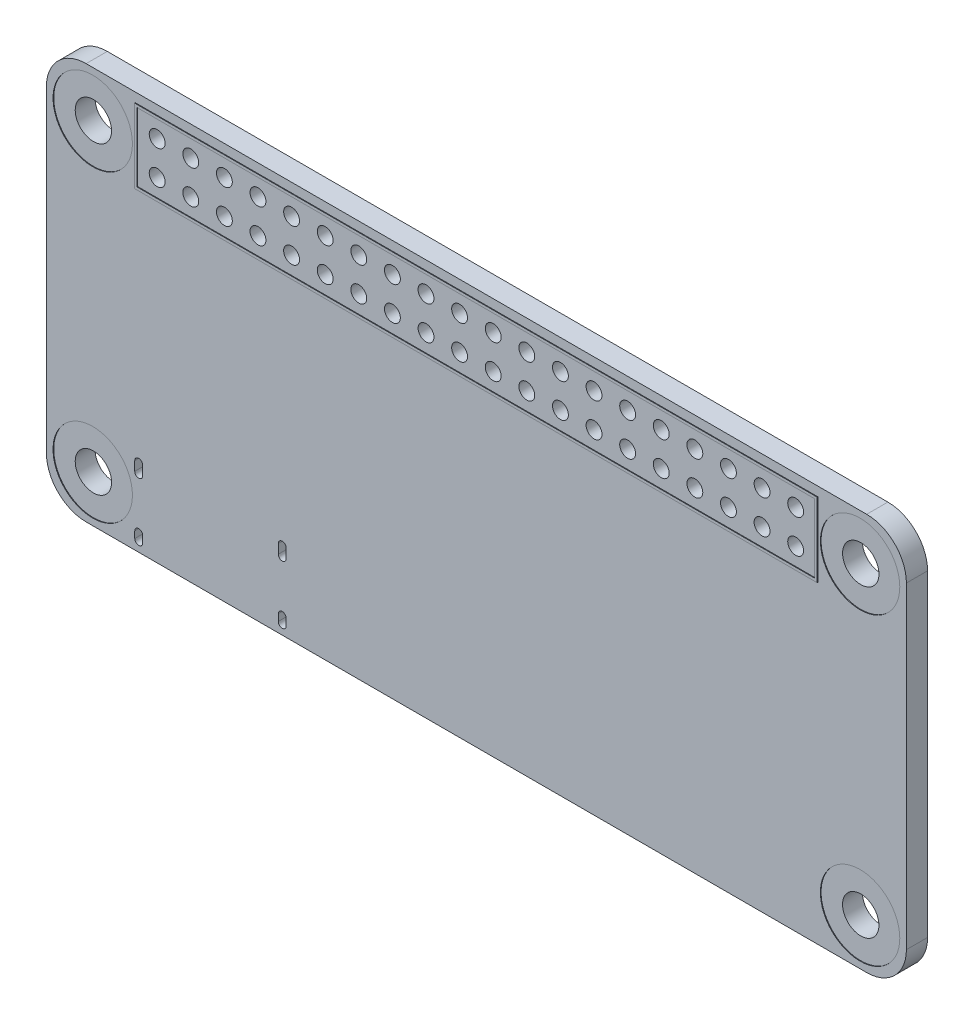
from build123d import *

# Parameters (mm, degrees)
SKETCH1_R           = 1.375
BOSS_EXTRUDE1_DEPTH = 1.6
SKETCH2_W           = 51.6
SKETCH2_H           = 5.6
SKETCH2_W_2         = 51.2
SKETCH2_H_2         = 5.2
EXTRUDE_THIN1_DEPTH = 0.05
SKETCH3_R           = 0.6
CUT_EXTRUDE1_DEPTH  = 1.6
SKETCH4_R           = 3
CUT_EXTRUDE2_DEPTH  = 0.05
SKETCH5_R           = 3
CUT_EXTRUDE3_DEPTH  = 0.05
CUT_EXTRUDE4_DEPTH  = 1.6


with BuildPart() as part:
    # Sketch1 → Boss-Extrude1 (new body)
    with BuildSketch(Plane.XY):
        with BuildLine():
            Line((-29.5, 15), (29.5, 15))
            ThreePointArc((29.5, 15), (31.621320344, 14.121320344), (32.5, 12))
            Line((32.5, 12), (32.5, -12))
            ThreePointArc((32.5, -12), (31.621320344, -14.121320344), (29.5, -15))
            Line((29.5, -15), (-29.5, -15))
            ThreePointArc((-29.5, -15), (-31.621320344, -14.121320344), (-32.5, -12))
            Line((-32.5, -12), (-32.5, 12))
            ThreePointArc((-32.5, 12), (-31.621320344, 14.121320344), (-29.5, 15))
        make_face()
        with Locations((-29, 11.5)):
            Circle(SKETCH1_R, mode=Mode.SUBTRACT)
        with Locations((29, 11.5)):
            Circle(SKETCH1_R, mode=Mode.SUBTRACT)
        with Locations((29, -11.5)):
            Circle(SKETCH1_R, mode=Mode.SUBTRACT)
        with Locations((-29, -11.5)):
            Circle(SKETCH1_R, mode=Mode.SUBTRACT)
    extrude(amount=BOSS_EXTRUDE1_DEPTH)

    # Sketch3 → Cut-Extrude1 (cut)
    with BuildSketch(Plane.XY.offset(1.6)):
        with Locations((-1.27, 12.77)):
            Circle(SKETCH3_R)
        with Locations((-3.81, 12.77)):
            Circle(SKETCH3_R)
        with Locations((-6.35, 12.77)):
            Circle(SKETCH3_R)
        with Locations((-8.89, 12.77)):
            Circle(SKETCH3_R)
        with Locations((-11.43, 12.77)):
            Circle(SKETCH3_R)
        with Locations((-13.97, 12.77)):
            Circle(SKETCH3_R)
        with Locations((-16.51, 12.77)):
            Circle(SKETCH3_R)
        with Locations((-19.05, 12.77)):
            Circle(SKETCH3_R)
        with Locations((-21.59, 12.77)):
            Circle(SKETCH3_R)
        with Locations((-24.13, 12.77)):
            Circle(SKETCH3_R)
        with Locations((-24.13, 10.23)):
            Circle(SKETCH3_R)
        with Locations((-21.59, 10.23)):
            Circle(SKETCH3_R)
        with Locations((-19.05, 10.23)):
            Circle(SKETCH3_R)
        with Locations((-16.51, 10.23)):
            Circle(SKETCH3_R)
        with Locations((-13.97, 10.23)):
            Circle(SKETCH3_R)
        with Locations((-11.43, 10.23)):
            Circle(SKETCH3_R)
        with Locations((-8.89, 10.23)):
            Circle(SKETCH3_R)
        with Locations((-6.35, 10.23)):
            Circle(SKETCH3_R)
        with Locations((-3.81, 10.23)):
            Circle(SKETCH3_R)
        with Locations((-1.27, 10.23)):
            Circle(SKETCH3_R)
        with Locations((24.13, 10.23)):
            Circle(SKETCH3_R)
        with Locations((24.13, 12.77)):
            Circle(SKETCH3_R)
        with Locations((21.59, 12.77)):
            Circle(SKETCH3_R)
        with Locations((21.59, 10.23)):
            Circle(SKETCH3_R)
        with Locations((19.05, 10.23)):
            Circle(SKETCH3_R)
        with Locations((19.05, 12.77)):
            Circle(SKETCH3_R)
        with Locations((16.51, 12.77)):
            Circle(SKETCH3_R)
        with Locations((16.51, 10.23)):
            Circle(SKETCH3_R)
        with Locations((13.97, 10.23)):
            Circle(SKETCH3_R)
        with Locations((13.97, 12.77)):
            Circle(SKETCH3_R)
        with Locations((11.43, 12.77)):
            Circle(SKETCH3_R)
        with Locations((11.43, 10.23)):
            Circle(SKETCH3_R)
        with Locations((8.89, 10.23)):
            Circle(SKETCH3_R)
        with Locations((8.89, 12.77)):
            Circle(SKETCH3_R)
        with Locations((6.35, 12.77)):
            Circle(SKETCH3_R)
        with Locations((6.35, 10.23)):
            Circle(SKETCH3_R)
        with Locations((3.81, 10.23)):
            Circle(SKETCH3_R)
        with Locations((3.81, 12.77)):
            Circle(SKETCH3_R)
        with Locations((1.27, 12.77)):
            Circle(SKETCH3_R)
        with Locations((1.27, 10.23)):
            Circle(SKETCH3_R)
    extrude(amount=-CUT_EXTRUDE1_DEPTH, mode=Mode.SUBTRACT)

    # Sketch4 → Cut-Extrude2 (cut)
    with BuildSketch(Plane.XY.offset(1.6)):
        with Locations((-29, 11.5)):
            Circle(SKETCH4_R)
        with Locations((-29, -11.5)):
            Circle(SKETCH4_R)
        with Locations((29, -11.5)):
            Circle(SKETCH4_R)
        with Locations((29, 11.5)):
            Circle(SKETCH4_R)
    extrude(amount=-CUT_EXTRUDE2_DEPTH, mode=Mode.SUBTRACT)

    # Sketch5 → Cut-Extrude3 (cut)
    with BuildSketch(Plane(origin=(0, 0, 0), x_dir=(-1, 0, 0), z_dir=(0, 0, -1))):
        with Locations((-29, 11.5)):
            Circle(SKETCH5_R)
        with Locations((-29, -11.5)):
            Circle(SKETCH5_R)
        with Locations((29, -11.5)):
            Circle(SKETCH5_R)
        with Locations((29, 11.5)):
            Circle(SKETCH5_R)
    extrude(amount=-CUT_EXTRUDE3_DEPTH, mode=Mode.SUBTRACT)

    # Sketch6 → Cut-Extrude4 (cut)
    with BuildSketch(Plane(origin=(0, 0, 0), x_dir=(-1, 0, 0), z_dir=(0, 0, -1))):
        with BuildLine():
            Line((14.975, -9.15), (14.975, -9.85))
            ThreePointArc((14.975, -9.85), (14.675, -10.15), (14.375, -9.85))
            Line((14.375, -9.85), (14.375, -9.15))
            ThreePointArc((14.375, -9.15), (14.675, -8.85), (14.975, -9.15))
        make_face()
        with BuildLine():
            Line((14.975, -13.75), (14.975, -14.25))
            ThreePointArc((14.975, -14.25), (14.675, -14.55), (14.375, -14.25))
            Line((14.375, -14.25), (14.375, -13.75))
            ThreePointArc((14.375, -13.75), (14.675, -13.45), (14.975, -13.75))
        make_face()
        with BuildLine():
            Line((25.825, -9.15), (25.825, -9.85))
            ThreePointArc((25.825, -9.85), (25.525, -10.15), (25.225, -9.85))
            Line((25.225, -9.85), (25.225, -9.15))
            ThreePointArc((25.225, -9.15), (25.525, -8.85), (25.825, -9.15))
        make_face()
        with BuildLine():
            Line((25.825, -13.75), (25.825, -14.25))
            ThreePointArc((25.825, -14.25), (25.525, -14.55), (25.225, -14.25))
            Line((25.225, -14.25), (25.225, -13.75))
            ThreePointArc((25.225, -13.75), (25.525, -13.45), (25.825, -13.75))
        make_face()
    extrude(amount=-CUT_EXTRUDE4_DEPTH, mode=Mode.SUBTRACT)


with BuildPart() as body_2:
    # Sketch2 → Extrude-Thin1 (new body)
    with BuildSketch(Plane.XY.offset(1.6)):
        with Locations((0, 11.5)):
            Rectangle(SKETCH2_W, SKETCH2_H)
        with Locations((0, 11.5)):
            Rectangle(SKETCH2_W_2, SKETCH2_H_2, mode=Mode.SUBTRACT)
    extrude(amount=EXTRUDE_THIN1_DEPTH)


solid = Compound([part.part, body_2.part])
